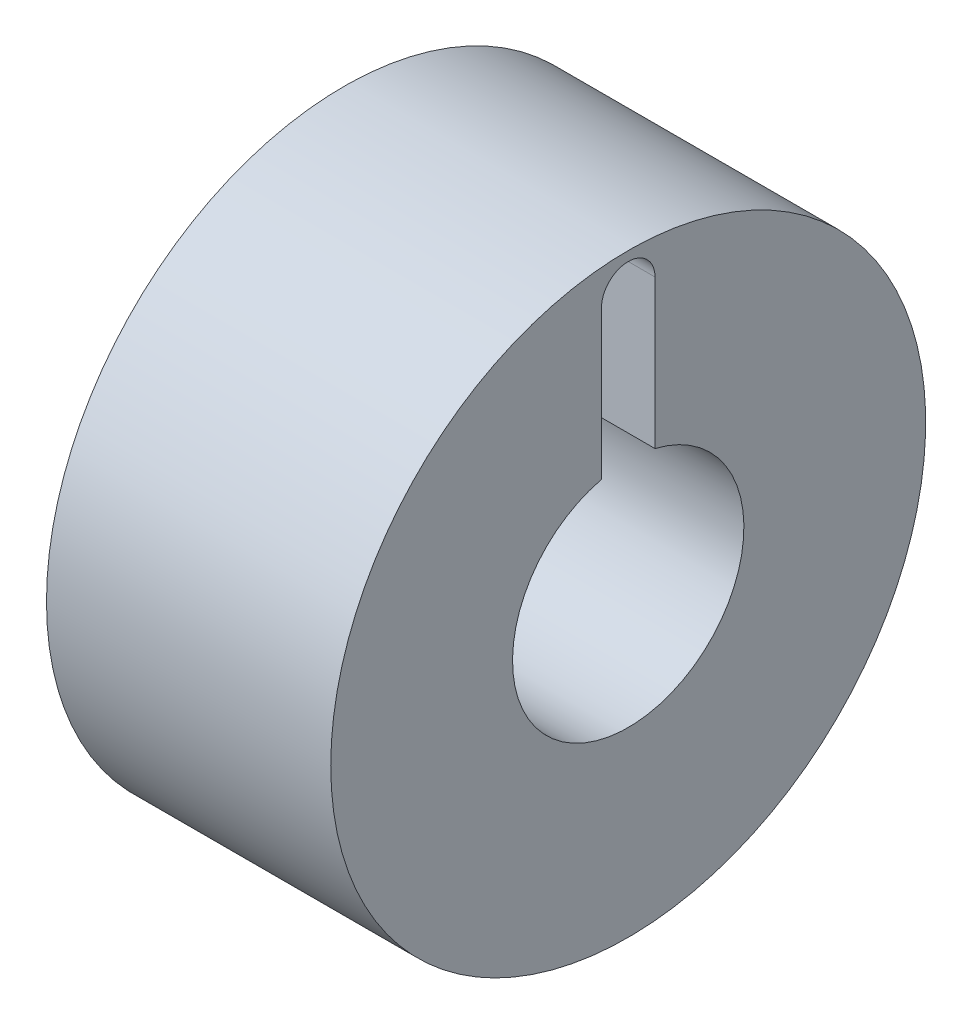
from build123d import *

# Parameters (mm, degrees)
CUT_EXTRUDE1_REACH = 10.6


with BuildPart() as part:
    # Sketch3 → Revolve1 (revolve)
    with BuildSketch(Plane.XY):
        Polygon((253.385153788, -140.873704322), (253.385153788, -145.073704322), (259.285153788, -145.073704322), (259.285153788, -140.857236748), (259.285153788, -139.573704322), (250.685153788, -139.573704322), (250.685153788, -140.873704322), align=None)
    revolve(axis=Axis((227.370475166, -148.573704322, 0), (1, 0, 0)))

    # Sketch11 → Cut-Extrude1 (cut, up to next)
    with BuildSketch(Plane(origin=(259.285153788, 0, 0), x_dir=(0, 0, -1), z_dir=(1, 0, 0)), mode=Mode.PRIVATE) as cut_extrude1_sk1:
        with BuildLine():
            Line((-0.810006034, -140.673704322), (-0.810006034, -145.168724113))
            Line((-0.810006034, -145.168724113), (0.810006034, -145.168724113))
            Line((0.810006034, -145.168724113), (0.810006034, -140.673704322))
            ThreePointArc((0.810006034, -140.673704322), (0, -139.863698288), (-0.810006034, -140.673704322))
        make_face()
    cut_extrude1_tool1 = extrude(cut_extrude1_sk1.sketch, amount=-CUT_EXTRUDE1_REACH, mode=Mode.PRIVATE) & part.part
    add(cut_extrude1_tool1.solids().sort_by_distance((259.285154, -142.599941, 0))[0], mode=Mode.SUBTRACT)


solid = part.part
